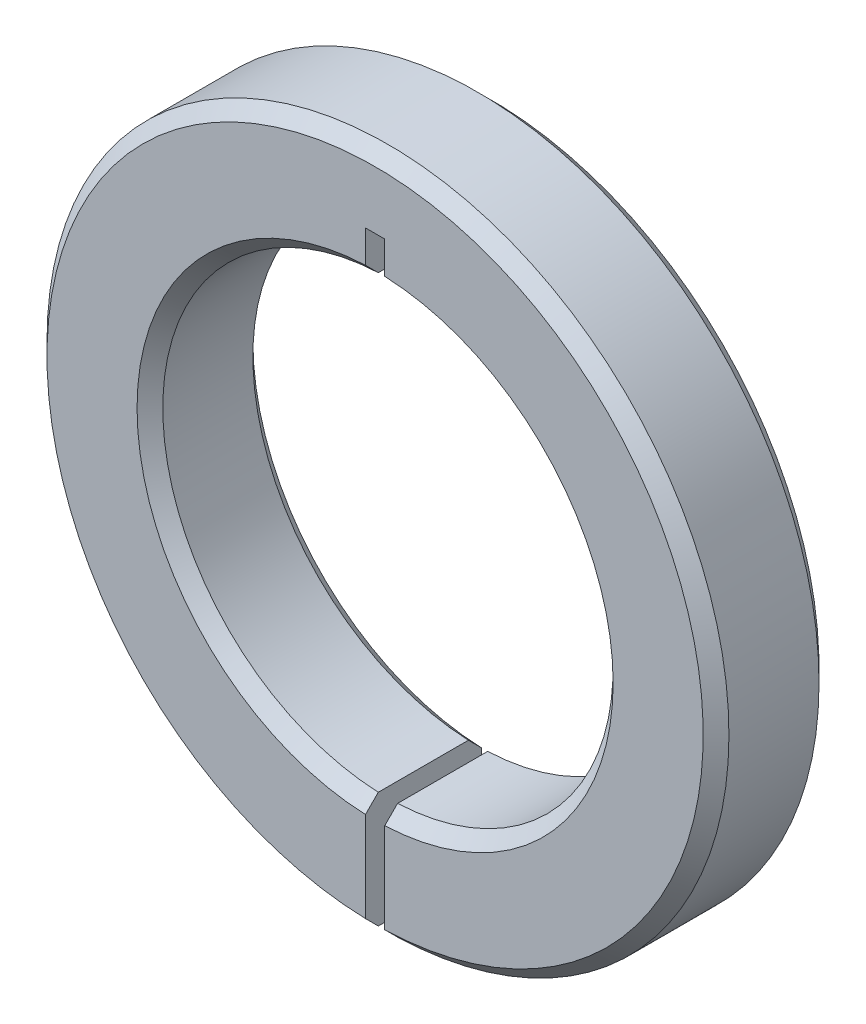
from build123d import *

# Parameters (mm, degrees)
BOSS_EXTRUDE1_DEPTH = 9
CHAMFER1_SIZE       = 1
SKETCH2_R           = 2
CUT_EXTRUDE1_DEPTH  = 7
SKETCH3_R           = 3
CUT_EXTRUDE2_DEPTH  = 20.5


with BuildPart() as part:
    # Sketch1 → Boss-Extrude1 (new body)
    with BuildSketch(Plane.XY):
        with BuildLine():
            Line((-0.75, 21), (0.75, 21))
            Line((0.75, 21), (0.75, 17.483921185))
            ThreePointArc((0.75, 17.483921185), (17.5, 0), (0.75, -17.483921185))
            Line((0.75, -17.483921185), (0.75, -26.489384666))
            ThreePointArc((0.75, -26.489384666), (0, 26.5), (-0.75, -26.489384666))
            Line((-0.75, -26.489384666), (-0.75, -17.483921185))
            ThreePointArc((-0.75, -17.483921185), (-17.5, 0), (-0.75, 17.483921185))
            Line((-0.75, 17.483921185), (-0.75, 21))
        make_face()
    extrude(amount=BOSS_EXTRUDE1_DEPTH)

    # Chamfer1
    chamfer1_edges = [part.edges().sort_by_distance(p)[0] for p in [
        (0, 26.5, 0),
        (17.5, 0, 0),
        (0, 26.5, 9),
        (-17.5, 0, 9),
        (17.5, 0, 9),
        (-17.5, 0, 0),
    ]]
    chamfer(chamfer1_edges, length=CHAMFER1_SIZE)

    # Sketch2 → Cut-Extrude1 (cut, symmetric)
    with BuildSketch(Plane(origin=(0, 0, 0), x_dir=(0, 0, -1), z_dir=(1, 0, 0))):
        with Locations((-4.5, -22)):
            Circle(SKETCH2_R)
    extrude(amount=CUT_EXTRUDE1_DEPTH, both=True, mode=Mode.SUBTRACT)

    # Sketch3 → Cut-Extrude2 (cut, through all)
    with BuildSketch(Plane(origin=(7, 0, 0), x_dir=(0, 0, -1), z_dir=(1, 0, 0))):
        with Locations((-4.5, -22)):
            Circle(SKETCH3_R)
    cut_extrude2 = extrude(amount=CUT_EXTRUDE2_DEPTH, mode=Mode.SUBTRACT)

    # Mirror1: Cut-Extrude2 across plane
    add(cut_extrude2.mirror(Plane(origin=(0, 0, 0), x_dir=(0, 0, 1), z_dir=(1, 0, 0))), mode=Mode.SUBTRACT)


solid = part.part
